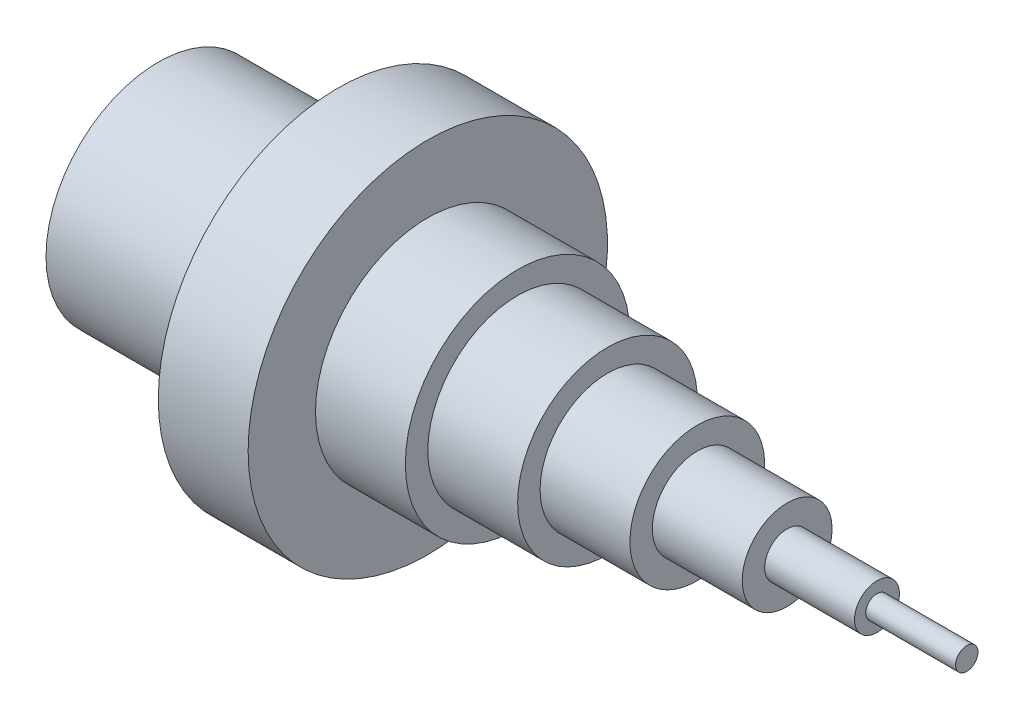
from build123d import *

# Parameters (mm, degrees)
SKETCH3_R          = 20
CUT_EXTRUDE1_DEPTH = 40


with BuildPart() as part:
    # Sketch2 → Revolve1 (revolve)
    with BuildSketch(Plane(origin=(0, 0, 0), x_dir=(1, 0, 0), z_dir=(0, 1, 0))):
        Polygon((0, 0), (0, -25), (40, -25), (40, -40), (60, -40), (60, -25), (80, -25), (80, -20), (100, -20), (100, -15), (120, -15), (120, -10), (140, -10), (140, -5), (160, -5), (160, -2.5), (180, -2.5), (180, 0), align=None)
    revolve(axis=Axis((0, 0, 0), (1, 0, 0)))

    # Sketch3 → Cut-Extrude1 (cut)
    with BuildSketch(Plane.ZY):
        Circle(SKETCH3_R)
    extrude(amount=-CUT_EXTRUDE1_DEPTH, mode=Mode.SUBTRACT)


solid = part.part
